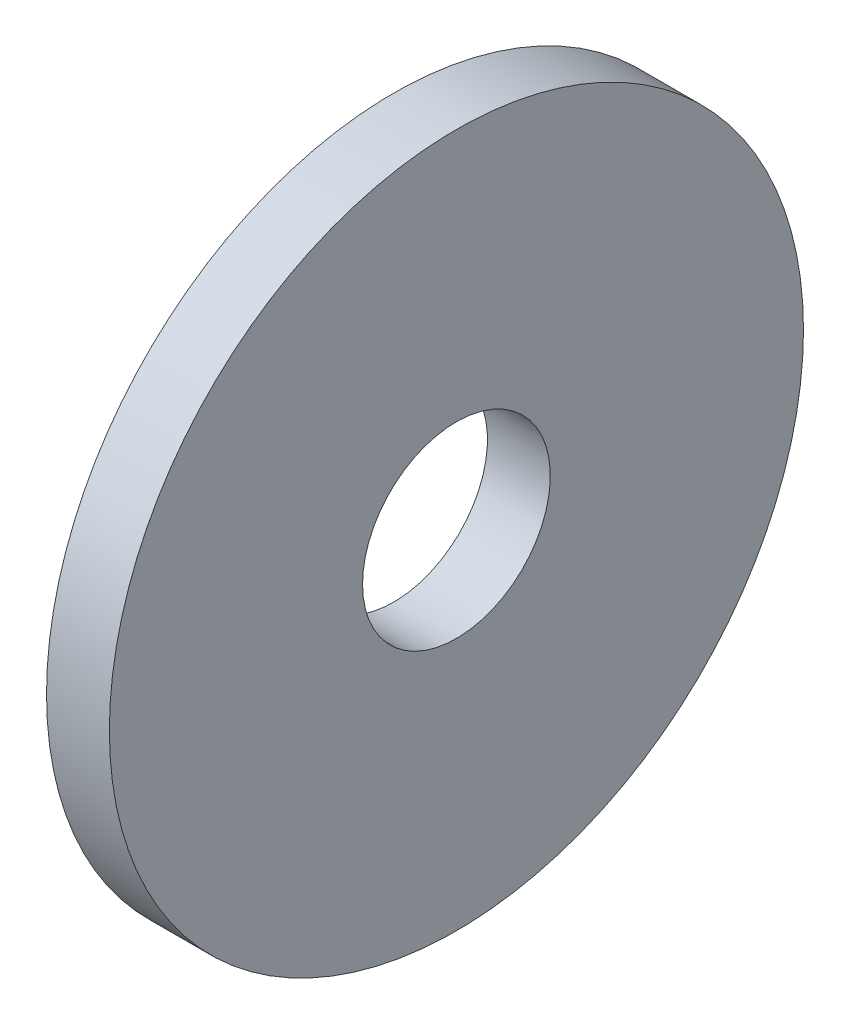
from build123d import *

# Parameters (mm, degrees)
SKETCH1_W = 2.3
SKETCH1_H = 9.265


with BuildPart() as part:
    # Sketch1 → Base-Revolve (revolve)
    with BuildSketch(Plane.XY):
        with Locations((-1.15, 8.0675)):
            Rectangle(SKETCH1_W, SKETCH1_H)
    revolve(axis=Axis((-34.925, 0, 0), (1, 0, 0)))


solid = part.part
